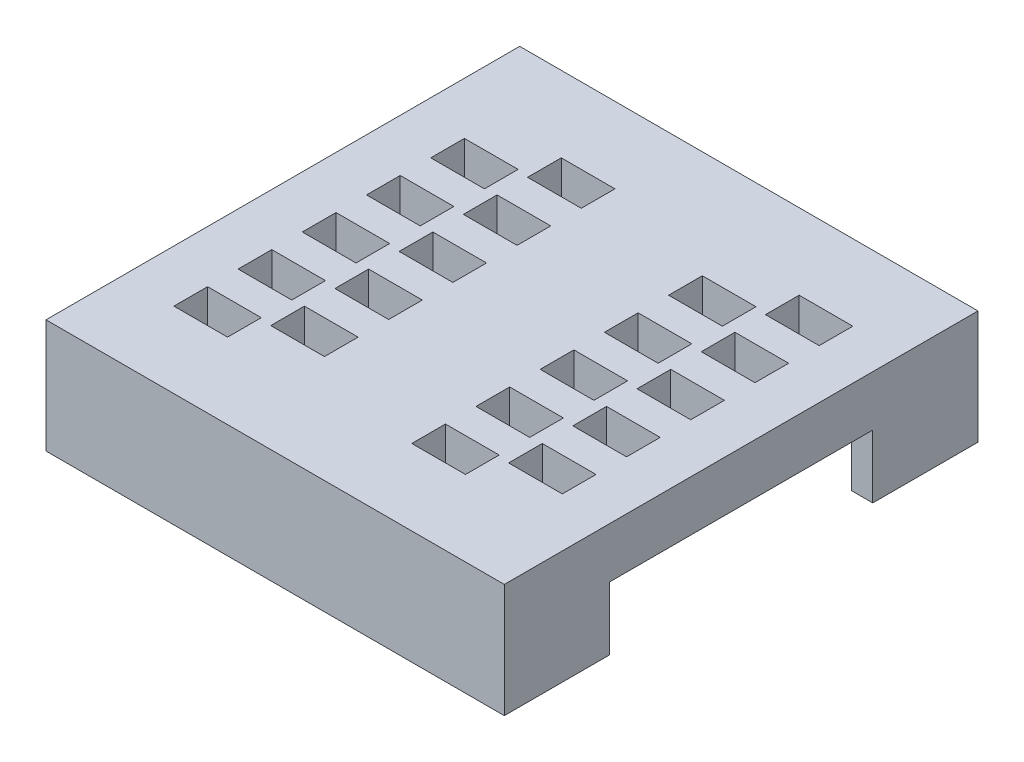
from build123d import *

# Parameters (mm, degrees)
SKETCH_1_W          = 43.5396
SKETCH_1_H          = 45
SKETCH_1_W_2        = 5.1
SKETCH_1_H_2        = 3.2
EXTRUDE_1_DEPTH     = 3.2
SKETCH_2_W          = 43.5396
SKETCH_2_H          = 45
SKETCH_2_R          = 0.5
SKETCH_2_W_2        = 5.6
SKETCH_2_H_2        = 5.6
EXTRUDE_3_DEPTH     = 0.6
SKETCH_3_R          = 5
SKETCH_3_R_2        = 0.5
EXTRUDE_4_DEPTH     = 1
SKETCH_4_W          = 43.5396
SKETCH_4_H          = 45
SKETCH_4_W_2        = 39.5396
SKETCH_4_H_2        = 41
EXTRUDE_6_DEPTH     = 7
SKETCH_6_W          = 2
SKETCH_6_H          = 25
CUT_EXTRUDE_2_DEPTH = 6
SKETCH_8_W          = 0.666666666
SKETCH_8_H          = 0.76923077
SKETCH_8_W_2        = 2.923076924
CUT_EXTRUDE_4_DEPTH = 0.2


with BuildPart() as part:
    # Эскиз1 → Бобышка-Вытянуть1 (new body)
    with BuildSketch(Plane(origin=(0, 0, 0), x_dir=(1, 0, 0), z_dir=(0, 1, 0))):
        with Locations((24.572876455, 25.0812132)):
            Rectangle(SKETCH_1_W, SKETCH_1_H)
        with Locations((16.503076455, 38.7809132)):
            Rectangle(SKETCH_1_W_2, SKETCH_1_H_2, mode=Mode.SUBTRACT)
        with Locations((39.103076455, 38.7809132)):
            Rectangle(SKETCH_1_W_2, SKETCH_1_H_2, mode=Mode.SUBTRACT)
        with Locations((10.303076455, 35.7809132)):
            Rectangle(SKETCH_1_W_2, SKETCH_1_H_2, mode=Mode.SUBTRACT)
        with Locations((32.903076455, 35.7809132)):
            Rectangle(SKETCH_1_W_2, SKETCH_1_H_2, mode=Mode.SUBTRACT)
        with Locations((16.503076455, 32.6809132)):
            Rectangle(SKETCH_1_W_2, SKETCH_1_H_2, mode=Mode.SUBTRACT)
        with Locations((39.103076455, 32.6809132)):
            Rectangle(SKETCH_1_W_2, SKETCH_1_H_2, mode=Mode.SUBTRACT)
        with Locations((10.303076455, 29.6809132)):
            Rectangle(SKETCH_1_W_2, SKETCH_1_H_2, mode=Mode.SUBTRACT)
        with Locations((32.903076455, 29.6809132)):
            Rectangle(SKETCH_1_W_2, SKETCH_1_H_2, mode=Mode.SUBTRACT)
        with Locations((39.103076455, 26.5809132)):
            Rectangle(SKETCH_1_W_2, SKETCH_1_H_2, mode=Mode.SUBTRACT)
        with Locations((16.503076455, 26.5809132)):
            Rectangle(SKETCH_1_W_2, SKETCH_1_H_2, mode=Mode.SUBTRACT)
        with Locations((10.303076455, 23.5809132)):
            Rectangle(SKETCH_1_W_2, SKETCH_1_H_2, mode=Mode.SUBTRACT)
        with Locations((32.903076455, 23.5809132)):
            Rectangle(SKETCH_1_W_2, SKETCH_1_H_2, mode=Mode.SUBTRACT)
        with Locations((39.103076455, 20.4809132)):
            Rectangle(SKETCH_1_W_2, SKETCH_1_H_2, mode=Mode.SUBTRACT)
        with Locations((16.503076455, 20.4809132)):
            Rectangle(SKETCH_1_W_2, SKETCH_1_H_2, mode=Mode.SUBTRACT)
        with Locations((32.903076455, 17.4809132)):
            Rectangle(SKETCH_1_W_2, SKETCH_1_H_2, mode=Mode.SUBTRACT)
        with Locations((10.303076455, 17.4809132)):
            Rectangle(SKETCH_1_W_2, SKETCH_1_H_2, mode=Mode.SUBTRACT)
        with Locations((16.503076455, 14.3809132)):
            Rectangle(SKETCH_1_W_2, SKETCH_1_H_2, mode=Mode.SUBTRACT)
        with Locations((10.303076455, 11.3809132)):
            Rectangle(SKETCH_1_W_2, SKETCH_1_H_2, mode=Mode.SUBTRACT)
        with Locations((32.903076455, 11.3809132)):
            Rectangle(SKETCH_1_W_2, SKETCH_1_H_2, mode=Mode.SUBTRACT)
        with Locations((39.103076455, 14.3809132)):
            Rectangle(SKETCH_1_W_2, SKETCH_1_H_2, mode=Mode.SUBTRACT)
    extrude(amount=EXTRUDE_1_DEPTH)

    # Эскиз2 → Бобышка-Вытянуть3 (add)
    with BuildSketch(Plane(origin=(0, 0, 0), x_dir=(1, 0, 0), z_dir=(0, 1, 0))):
        with Locations((24.572876455, 25.0812132)):
            Rectangle(SKETCH_2_W, SKETCH_2_H)
        with Locations((7.803076455, 42.5812132)):
            Circle(SKETCH_2_R, mode=Mode.SUBTRACT)
        with Locations((41.342676455, 42.5812132)):
            Circle(SKETCH_2_R, mode=Mode.SUBTRACT)
        with Locations((41.342676455, 7.5812132)):
            Circle(SKETCH_2_R, mode=Mode.SUBTRACT)
        with Locations((7.803076455, 7.5812132)):
            Circle(SKETCH_2_R, mode=Mode.SUBTRACT)
        with Locations((16.503076455, 38.7812132)):
            Rectangle(SKETCH_2_W_2, SKETCH_2_H_2, mode=Mode.SUBTRACT)
        with Locations((16.503076455, 32.624117539)):
            Rectangle(SKETCH_2_W_2, SKETCH_2_H_2, mode=Mode.SUBTRACT)
        with Locations((16.503076455, 26.5812132)):
            Rectangle(SKETCH_2_W_2, SKETCH_2_H_2, mode=Mode.SUBTRACT)
        with Locations((16.503076455, 20.4812132)):
            Rectangle(SKETCH_2_W_2, SKETCH_2_H_2, mode=Mode.SUBTRACT)
        with Locations((16.503076455, 14.3812132)):
            Rectangle(SKETCH_2_W_2, SKETCH_2_H_2, mode=Mode.SUBTRACT)
        with Locations((32.903076455, 11.3812132)):
            Rectangle(SKETCH_2_W_2, SKETCH_2_H_2, mode=Mode.SUBTRACT)
        with Locations((32.903076455, 17.4812132)):
            Rectangle(SKETCH_2_W_2, SKETCH_2_H_2, mode=Mode.SUBTRACT)
        with Locations((32.903076455, 23.5812132)):
            Rectangle(SKETCH_2_W_2, SKETCH_2_H_2, mode=Mode.SUBTRACT)
        with Locations((32.903076455, 29.6812132)):
            Rectangle(SKETCH_2_W_2, SKETCH_2_H_2, mode=Mode.SUBTRACT)
        with Locations((32.903076455, 35.7812132)):
            Rectangle(SKETCH_2_W_2, SKETCH_2_H_2, mode=Mode.SUBTRACT)
    extrude(amount=-EXTRUDE_3_DEPTH)

    # Эскиз3 → Бобышка-Вытянуть4 (add)
    with BuildSketch(Plane.XZ.offset(0.6)):
        with Locations((7.803076455, -7.5812132)):
            Circle(SKETCH_3_R)
        with Locations((7.803076455, -7.5812132)):
            Circle(SKETCH_3_R_2, mode=Mode.SUBTRACT)
        with Locations((41.342676455, -7.5812132)):
            Circle(SKETCH_3_R)
        with Locations((41.342676455, -7.5812132)):
            Circle(SKETCH_3_R_2, mode=Mode.SUBTRACT)
        with Locations((41.342676455, -42.5812132)):
            Circle(SKETCH_3_R)
        with Locations((41.342676455, -42.5812132)):
            Circle(SKETCH_3_R_2, mode=Mode.SUBTRACT)
        with Locations((7.803076455, -42.5812132)):
            Circle(SKETCH_3_R)
        with Locations((7.803076455, -42.5812132)):
            Circle(SKETCH_3_R_2, mode=Mode.SUBTRACT)
    extrude(amount=EXTRUDE_4_DEPTH)

    # Эскиз4 → Бобышка-Вытянуть6 (add)
    with BuildSketch(Plane.XZ.offset(0.6)):
        with Locations((24.572876455, -25.0812132)):
            Rectangle(SKETCH_4_W, SKETCH_4_H)
        with Locations((24.572876455, -25.0812132)):
            Rectangle(SKETCH_4_W_2, SKETCH_4_H_2, mode=Mode.SUBTRACT)
    extrude(amount=EXTRUDE_6_DEPTH)

    # Эскиз6 → Вырез-Вытянуть2 (cut)
    with BuildSketch(Plane.XZ.offset(7.6)):
        with Locations((3.803076455, -25.0812132)):
            Rectangle(SKETCH_6_W, SKETCH_6_H)
        with Locations((45.342676455, -25.0812132)):
            Rectangle(SKETCH_6_W, SKETCH_6_H)
    extrude(amount=-CUT_EXTRUDE_2_DEPTH, mode=Mode.SUBTRACT)

    # Эскиз8 → Вырез-Вытянуть4 (cut)
    with BuildSketch(Plane.XZ.offset(0.6)):
        with BuildLine():
            Line((22.803076455, -17.437559656), (22.803076455, -16.668328887))
            Line((22.803076455, -16.668328887), (23.225352096, -16.668328887))
            add(Edge.make_bspline(
                [(23.225352096, -16.668328887), (23.186037635, -16.640249012), (23.109623847, -16.585671397), (23.011636099, -16.48835605), (22.927633688, -16.386202085), (22.862878338, -16.275193724), (22.813636699, -16.161029567), (22.777804078, -16.045577461), (22.756203694, -15.92928801), (22.753260637, -15.851375651), (22.751794404, -15.812559656)],
                knots=[0, 0, 0, 0, 0.000144713, 0.000281272, 0.000412919, 0.000540446, 0.000665336, 0.000785221, 0.000902471, 0.001018881, 0.001018881, 0.001018881, 0.001018881], degree=3))
            add(Edge.make_bspline(
                [(22.751794404, -15.812559656), (22.753114243, -15.774038075), (22.755732457, -15.697621352), (22.773947574, -15.585161556), (22.807014692, -15.477430914), (22.85086947, -15.373737911), (22.907960308, -15.274253997), (22.976625811, -15.17860401), (23.05995328, -15.088655398), (23.153417868, -15.002274282), (23.259379923, -14.924093411), (23.37497246, -14.854682088), (23.501155539, -14.79694285), (23.63698816, -14.749835125), (23.782848054, -14.713055223), (23.938492059, -14.686746063), (24.104065225, -14.671785841), (24.217576453, -14.669501341), (24.275832866, -14.668328887)],
                knots=[0, 0, 0, 0, 0.000115563, 0.000229246, 0.000340532, 0.0004529, 0.0005663, 0.000683947, 0.00080533, 0.000933505, 0.001065238, 0.001199633, 0.001337305, 0.001480736, 0.001630379, 0.001788061, 0.001953825, 0.002128595, 0.002128595, 0.002128595, 0.002128595], degree=3))
            add(Edge.make_bspline(
                [(24.275832866, -14.668328887), (24.335423994, -14.669494736), (24.451067804, -14.671757209), (24.619055365, -14.686636933), (24.775773468, -14.71298266), (24.921661804, -14.749718407), (25.056724482, -14.796820967), (25.18119295, -14.854368041), (25.293784325, -14.923692762), (25.395092545, -15.002456968), (25.484702263, -15.089011869), (25.563143362, -15.18145491), (25.62911697, -15.280028589), (25.684295407, -15.383588703), (25.726079133, -15.49353784), (25.755251544, -15.608650295), (25.774874351, -15.729091921), (25.776570005, -15.811411123), (25.77743543, -15.853425041)],
                knots=[0, 0, 0, 0, 0.000178774, 0.000346932, 0.000505404, 0.000655047, 0.000797722, 0.00093394, 0.001065594, 0.001193499, 0.001318169, 0.001438719, 0.001556505, 0.001673352, 0.00179002, 0.001908377, 0.002029182, 0.002155108, 0.002155108, 0.002155108, 0.002155108], degree=3))
            add(Edge.make_bspline(
                [(25.77743543, -15.853425041), (25.776187089, -15.892229818), (25.773727633, -15.96868221), (25.754633801, -16.081361273), (25.723678883, -16.189915818), (25.678609093, -16.294096292), (25.622490944, -16.39490195), (25.553028692, -16.491038977), (25.471436488, -16.583429712), (25.409423222, -16.639534039), (25.377595686, -16.668328887)],
                knots=[0, 0, 0, 0, 0.000116363, 0.000229255, 0.000341852, 0.00045422, 0.000569016, 0.000687313, 0.000809353, 0.00093803, 0.00093803, 0.00093803, 0.00093803], degree=3))
            Line((25.377595686, -16.668328887), (26.803076455, -16.668328887))
            Line((26.803076455, -16.668328887), (26.803076455, -17.437559656))
            Line((26.803076455, -17.437559656), (22.803076455, -17.437559656))
        make_face()
        with BuildLine():
            add(Edge.make_bspline(
                [(24.319903379, -15.437559656), (24.281162804, -15.437685924), (24.206560259, -15.437929077), (24.098868363, -15.444843294), (23.999698249, -15.454248702), (23.908575819, -15.466499541), (23.825855053, -15.484132497), (23.751499301, -15.505736617), (23.684791651, -15.529924985), (23.645027831, -15.550911141), (23.625993122, -15.560957092)],
                knots=[0, 0, 0, 0, 0.000116197, 0.00022376, 0.000323583, 0.000415031, 0.000499425, 0.000577021, 0.000647265, 0.000711767, 0.000711767, 0.000711767, 0.000711767], degree=3))
            add(Edge.make_bspline(
                [(23.625993122, -15.560957092), (23.601241414, -15.575810985), (23.553347257, -15.604553028), (23.490712713, -15.656993574), (23.435927957, -15.711861393), (23.392449426, -15.773148598), (23.357368509, -15.83803226), (23.333486064, -15.907924354), (23.318445586, -15.981785709), (23.316759591, -16.032569959), (23.315896968, -16.058553246)],
                knots=[0, 0, 0, 0, 8.6468e-05, 0.000167314, 0.000244379, 0.000318431, 0.000391914, 0.000464897, 0.000539226, 0.000617099, 0.000617099, 0.000617099, 0.000617099], degree=3))
            add(Edge.make_bspline(
                [(23.315896968, -16.058553246), (23.31679995, -16.079420138), (23.318582326, -16.120608821), (23.32872754, -16.181140578), (23.347788772, -16.238850121), (23.373600842, -16.294074936), (23.405739883, -16.347761222), (23.446346159, -16.398189247), (23.493948131, -16.446391964), (23.548401932, -16.492109916), (23.610156931, -16.533966216), (23.679615877, -16.569936591), (23.756351358, -16.60061754), (23.840308362, -16.62454231), (23.930812537, -16.645454185), (24.028773459, -16.657957695), (24.13381546, -16.667565084), (24.206362763, -16.668068983), (24.243781584, -16.668328887)],
                knots=[0, 0, 0, 0, 6.2628e-05, 0.000123621, 0.000183422, 0.000244367, 0.000306206, 0.000370653, 0.00043808, 0.000509178, 0.000583628, 0.000661402, 0.000743388, 0.000831112, 0.000923065, 0.001021766, 0.001127103, 0.001239308, 0.001239308, 0.001239308, 0.001239308], degree=3))
            add(Edge.make_bspline(
                [(24.243781584, -16.668328887), (24.285195326, -16.667963686), (24.365169211, -16.667258449), (24.480731637, -16.659173751), (24.587555422, -16.645902198), (24.685241451, -16.626720212), (24.77411897, -16.603012036), (24.853938703, -16.573475231), (24.924681948, -16.538404859), (24.98658965, -16.498018665), (25.039489143, -16.452434507), (25.086247892, -16.404887834), (25.125133783, -16.35349909), (25.157569191, -16.299707049), (25.182671758, -16.242328925), (25.199960004, -16.18165307), (25.211985308, -16.118321496), (25.212880249, -16.0749031), (25.213332866, -16.052944271)],
                knots=[0, 0, 0, 0, 0.000124222, 0.000239884, 0.000347322, 0.000446952, 0.000538312, 0.000622998, 0.000701834, 0.000774729, 0.000844085, 0.000910952, 0.000974416, 0.001036941, 0.001099019, 0.001161647, 0.001225934, 0.001291718, 0.001291718, 0.001291718, 0.001291718], degree=3))
            add(Edge.make_bspline(
                [(25.213332866, -16.052944271), (25.212789456, -16.031533809), (25.211716275, -15.989250217), (25.201022848, -15.927331701), (25.18331783, -15.86809629), (25.158033501, -15.81186672), (25.126925991, -15.757716532), (25.087768111, -15.706921324), (25.041764512, -15.658687262), (24.988985893, -15.613238678), (24.929599649, -15.571090677), (24.862679302, -15.53531432), (24.789180435, -15.504663897), (24.708636101, -15.480012835), (24.621245246, -15.46092972), (24.526940834, -15.44778428), (24.425862434, -15.438354789), (24.355984962, -15.437830418), (24.319903379, -15.437559656)],
                knots=[0, 0, 0, 0, 6.4183e-05, 0.000126755, 0.000187847, 0.000249191, 0.000311309, 0.000374773, 0.000441086, 0.000510963, 0.000583433, 0.000659086, 0.000738104, 0.000821995, 0.000911426, 0.001006161, 0.001107506, 0.001215706, 0.001215706, 0.001215706, 0.001215706], degree=3))
        make_face(mode=Mode.SUBTRACT)
        with Locations((26.469743122, -18.642687861)):
            Rectangle(SKETCH_8_W, SKETCH_8_H)
        with Locations((24.264614917, -18.642687861)):
            Rectangle(SKETCH_8_W_2, SKETCH_8_H)
        with BuildLine():
            Line((25.726153379, -19.796534015), (25.726153379, -20.565764784))
            Line((25.726153379, -20.565764784), (25.30467902, -20.565764784))
            add(Edge.make_bspline(
                [(25.30467902, -20.565764784), (25.339518686, -20.588657143), (25.409008287, -20.634317194), (25.501569561, -20.718536511), (25.581986338, -20.815097089), (25.651726934, -20.921252245), (25.708086459, -21.036588407), (25.748065445, -21.159282011), (25.773071082, -21.288042482), (25.775964547, -21.376013155), (25.77743543, -21.420732733)],
                knots=[0, 0, 0, 0, 0.00012492, 0.00024916, 0.00037371, 0.000501056, 0.000629351, 0.000757566, 0.000887218, 0.001021272, 0.001021272, 0.001021272, 0.001021272], degree=3))
            add(Edge.make_bspline(
                [(25.77743543, -21.420732733), (25.77617725, -21.459802629), (25.773689763, -21.537045844), (25.754695085, -21.650471339), (25.724278581, -21.759739802), (25.680773848, -21.864463906), (25.624102022, -21.964212204), (25.555527488, -22.059261419), (25.474479955, -22.149505402), (25.382244354, -22.234688888), (25.278623047, -22.31267788), (25.16483239, -22.380828245), (25.040758179, -22.437767376), (24.907648015, -22.485359694), (24.764137136, -22.520655995), (24.611615067, -22.547459937), (24.449201649, -22.562283578), (24.337826731, -22.564583747), (24.280640558, -22.565764784)],
                knots=[0, 0, 0, 0, 0.000117163, 0.000231637, 0.000344013, 0.000456809, 0.000570907, 0.000687435, 0.000807745, 0.000934198, 0.001063525, 0.001196134, 0.001331287, 0.001472452, 0.001619567, 0.00177409, 0.001936663, 0.002108229, 0.002108229, 0.002108229, 0.002108229], degree=3))
            add(Edge.make_bspline(
                [(24.280640558, -22.565764784), (24.221837754, -22.56470628), (24.107477326, -22.562647689), (23.941242923, -22.54620756), (23.78473337, -22.520710041), (23.638741952, -22.481487307), (23.501686183, -22.434236249), (23.375389667, -22.374506491), (23.258781046, -22.304611642), (23.153728516, -22.22357911), (23.059282379, -22.135845135), (22.976886758, -22.042587653), (22.907610158, -21.944484152), (22.850910693, -21.84181281), (22.806642668, -21.734548424), (22.774210232, -21.62289645), (22.755597619, -21.50629307), (22.753074608, -21.427207688), (22.751794404, -21.387078887)],
                knots=[0, 0, 0, 0, 0.000176371, 0.000343009, 0.000500691, 0.000651511, 0.000795964, 0.000935039, 0.001069847, 0.001203026, 0.001332289, 0.00145606, 0.001575664, 0.001691861, 0.001807184, 0.001923082, 0.002039929, 0.002160292, 0.002160292, 0.002160292, 0.002160292], degree=3))
            add(Edge.make_bspline(
                [(22.751794404, -21.387078887), (22.752639788, -21.349055324), (22.754299474, -21.274406193), (22.774281949, -21.165584448), (22.801927333, -21.061463463), (22.84527722, -20.962050754), (22.902769091, -20.864547088), (22.9756812, -20.76544306), (23.065970637, -20.664492402), (23.134817053, -20.599693419), (23.170864917, -20.565764784)],
                knots=[0, 0, 0, 0, 0.00011392, 0.000223652, 0.000330967, 0.000436496, 0.000547814, 0.000669938, 0.00080502, 0.000953484, 0.000953484, 0.000953484, 0.000953484], degree=3))
            Line((23.170864917, -20.565764784), (21.726153379, -20.565764784))
            Line((21.726153379, -20.565764784), (21.726153379, -19.796534015))
            Line((21.726153379, -19.796534015), (25.726153379, -19.796534015))
        make_face()
        with BuildLine():
            add(Edge.make_bspline(
                [(24.314294404, -20.565764784), (24.273150717, -20.566492315), (24.193455359, -20.567901542), (24.078097864, -20.575506711), (23.970927221, -20.589628524), (23.872339445, -20.610873078), (23.78131112, -20.635615372), (23.699120744, -20.66809285), (23.62492036, -20.7053274), (23.559779712, -20.749023399), (23.502555691, -20.796540734), (23.45297847, -20.846826008), (23.410499147, -20.899514321), (23.375791074, -20.954817827), (23.349288692, -21.013138818), (23.329585173, -21.073786593), (23.318421242, -21.137203116), (23.316741596, -21.18030733), (23.315896968, -21.201982733)],
                knots=[0, 0, 0, 0, 0.000123439, 0.000239102, 0.000346644, 0.000447379, 0.000541485, 0.000629275, 0.000712056, 0.000790061, 0.000864031, 0.000934857, 0.001001556, 0.001066702, 0.001130165, 0.001193263, 0.001257551, 0.001322578, 0.001322578, 0.001322578, 0.001322578], degree=3))
            add(Edge.make_bspline(
                [(23.315896968, -21.201982733), (23.316440152, -21.222860081), (23.317512721, -21.264084394), (23.328206318, -21.324414752), (23.345927134, -21.382055666), (23.371215775, -21.436687129), (23.402355098, -21.489226511), (23.441474973, -21.538473363), (23.487559638, -21.584666992), (23.539516362, -21.629728574), (23.601093356, -21.668580849), (23.670808611, -21.703349238), (23.749366097, -21.733006687), (23.837374635, -21.755576819), (23.933990615, -21.774001252), (24.039411142, -21.787379747), (24.1539098, -21.795479963), (24.233083639, -21.796173555), (24.274230302, -21.796534015)],
                knots=[0, 0, 0, 0, 6.2582e-05, 0.000123574, 0.000183134, 0.000243016, 0.000303755, 0.000365951, 0.000431112, 0.000499339, 0.000571796, 0.00064884, 0.000732776, 0.000823154, 0.000921058, 0.001027701, 0.001141765, 0.001265186, 0.001265186, 0.001265186, 0.001265186], degree=3))
            add(Edge.make_bspline(
                [(24.274230302, -21.796534015), (24.31271582, -21.79627309), (24.387126919, -21.795768595), (24.494855048, -21.78623022), (24.595087898, -21.773401649), (24.68758071, -21.753743542), (24.773002634, -21.730589863), (24.849994374, -21.699733593), (24.919872781, -21.664646103), (24.981503443, -21.623431842), (25.036354612, -21.578912162), (25.082625269, -21.530169524), (25.123588714, -21.480476705), (25.156678894, -21.427496028), (25.181560744, -21.371210329), (25.200298661, -21.313029061), (25.210727059, -21.251762007), (25.212453001, -21.210299378), (25.213332866, -21.18916222)],
                knots=[0, 0, 0, 0, 0.00011541, 0.000223143, 0.000324225, 0.000418358, 0.00050663, 0.00058936, 0.000666766, 0.00074077, 0.000811356, 0.000878223, 0.000942045, 0.001004303, 0.001064915, 0.001126243, 0.001187236, 0.001250664, 0.001250664, 0.001250664, 0.001250664], degree=3))
            add(Edge.make_bspline(
                [(25.213332866, -21.18916222), (25.212897689, -21.167201335), (25.212042449, -21.124042216), (25.199881909, -21.060993269), (25.182490202, -21.000396692), (25.157820573, -20.942547735), (25.124886587, -20.888513018), (25.086305749, -20.836425086), (25.039548422, -20.788027551), (24.98651491, -20.741976971), (24.926327251, -20.700151254), (24.858689056, -20.664231379), (24.784418376, -20.63405428), (24.704006324, -20.607931598), (24.616154009, -20.589137319), (24.521596885, -20.576036196), (24.42025302, -20.566553778), (24.350375837, -20.566033455), (24.314294404, -20.565764784)],
                knots=[0, 0, 0, 0, 6.5783e-05, 0.000129282, 0.00019191, 0.000254723, 0.000317249, 0.000381351, 0.000448797, 0.000518674, 0.000591802, 0.000668159, 0.000747918, 0.000832049, 0.000921481, 0.001017008, 0.001118354, 0.001226554, 0.001226554, 0.001226554, 0.001226554], degree=3))
        make_face(mode=Mode.SUBTRACT)
        with BuildLine():
            Line((23.947307225, -22.976021194), (24.033845686, -23.642687861))
            add(Edge.make_bspline(
                [(24.033845686, -23.642687861), (23.988647068, -23.650084149), (23.901609681, -23.664326919), (23.779768738, -23.708176139), (23.673192798, -23.770687781), (23.582723505, -23.849384413), (23.509736579, -23.939156067), (23.45698064, -24.037831604), (23.42430572, -24.143311055), (23.420418254, -24.216444854), (23.418461071, -24.253264784)],
                knots=[0, 0, 0, 0, 0.000137188, 0.000264178, 0.000385936, 0.000505788, 0.000622043, 0.000731018, 0.000839771, 0.00095004, 0.00095004, 0.00095004, 0.00095004], degree=3))
            add(Edge.make_bspline(
                [(23.418461071, -24.253264784), (23.418836881, -24.274659003), (23.419572536, -24.316538515), (23.427925417, -24.378253311), (23.441491252, -24.437210609), (23.459918768, -24.493955543), (23.484095871, -24.547943525), (23.514008864, -24.59923729), (23.54864059, -24.648468452), (23.588285748, -24.695010356), (23.634442295, -24.73678113), (23.685496217, -24.773879359), (23.742672226, -24.804230098), (23.804377266, -24.830395547), (23.872422945, -24.848906189), (23.945148578, -24.863752685), (24.023541521, -24.871295181), (24.077369576, -24.872720982), (24.105159789, -24.873457092)],
                knots=[0, 0, 0, 0, 6.4148e-05, 0.00012557, 0.000186409, 0.000245449, 0.000304271, 0.000363506, 0.000423308, 0.000484668, 0.000546491, 0.000609645, 0.000673467, 0.000740281, 0.000810282, 0.000884612, 0.000962748, 0.001046143, 0.001046143, 0.001046143, 0.001046143], degree=3))
            add(Edge.make_bspline(
                [(24.105159789, -24.873457092), (24.131355716, -24.873041253), (24.181983663, -24.872237576), (24.255335009, -24.864781332), (24.323882528, -24.853336042), (24.387125001, -24.835128379), (24.446238235, -24.814333838), (24.499126639, -24.786297398), (24.548089279, -24.755534799), (24.590479141, -24.718037929), (24.627947977, -24.677188521), (24.661278539, -24.633659192), (24.689409867, -24.586869075), (24.712673071, -24.53726093), (24.730654653, -24.484620216), (24.742014114, -24.428832128), (24.750756752, -24.370523195), (24.751444878, -24.33049014), (24.751794404, -24.31015581)],
                knots=[0, 0, 0, 0, 7.8562e-05, 0.000151835, 0.000220996, 0.000286706, 0.000349073, 0.000408562, 0.000465903, 0.000522135, 0.000577708, 0.000632035, 0.000686316, 0.000741161, 0.000796147, 0.000852727, 0.000911767, 0.000972712, 0.000972712, 0.000972712, 0.000972712], degree=3))
            add(Edge.make_bspline(
                [(24.751794404, -24.31015581), (24.750872759, -24.284448486), (24.749034062, -24.233161971), (24.73408725, -24.157453858), (24.709753735, -24.083764051), (24.67587979, -24.012169142), (24.632194728, -23.942858547), (24.578553678, -23.876132347), (24.515879531, -23.810845151), (24.468524423, -23.770741967), (24.444102096, -23.750059656)],
                knots=[0, 0, 0, 0, 7.7073e-05, 0.000153762, 0.000230539, 0.000309395, 0.000390764, 0.000475734, 0.000565838, 0.000661794, 0.000661794, 0.000661794, 0.000661794], degree=3))
            Line((24.444102096, -23.750059656), (24.538653379, -23.078585297))
            Line((24.538653379, -23.078585297), (26.751794404, -23.540123758))
            Line((26.751794404, -23.540123758), (26.751794404, -25.488841707))
            Line((26.751794404, -25.488841707), (25.982563635, -25.488841707))
            Line((25.982563635, -25.488841707), (25.982563635, -24.157110938))
            Line((25.982563635, -24.157110938), (25.268621327, -24.000059656))
            add(Edge.make_bspline(
                [(25.268621327, -24.000059656), (25.291712285, -24.040080826), (25.336679772, -24.118018322), (25.382969675, -24.242446053), (25.41267928, -24.367512969), (25.41654378, -24.451821502), (25.418461071, -24.493649399)],
                knots=[0, 0, 0, 0, 0.000138388, 0.000269497, 0.000396823, 0.000522192, 0.000522192, 0.000522192, 0.000522192], degree=3))
            add(Edge.make_bspline(
                [(25.418461071, -24.493649399), (25.417402907, -24.532971178), (25.415312624, -24.610646923), (25.398162513, -24.724564886), (25.369897371, -24.833833871), (25.330563467, -24.938822852), (25.279006982, -25.038780876), (25.216693126, -25.134569647), (25.142540583, -25.224806267), (25.058690208, -25.310460293), (24.965919854, -25.388570754), (24.864758483, -25.456025351), (24.757725658, -25.514286592), (24.643638802, -25.561718148), (24.522339195, -25.597435469), (24.394871326, -25.624184289), (24.260430285, -25.63916879), (24.168763331, -25.641498855), (24.121986712, -25.642687861)],
                knots=[0, 0, 0, 0, 0.000117922, 0.000232941, 0.000344691, 0.000456011, 0.000568537, 0.000681438, 0.000798197, 0.00091832, 0.001040612, 0.001161287, 0.001282471, 0.001405684, 0.001531168, 0.001661287, 0.001795965, 0.001936301, 0.001936301, 0.001936301, 0.001936301], degree=3))
            add(Edge.make_bspline(
                [(24.121986712, -25.642687861), (24.0826958, -25.641622691), (24.004711191, -25.639508542), (23.889352397, -25.626932803), (23.777154446, -25.604092426), (23.668433007, -25.572862717), (23.562349787, -25.533487533), (23.46003618, -25.484512282), (23.360623383, -25.426540573), (23.297931279, -25.38171151), (23.266217481, -25.359034015)],
                knots=[0, 0, 0, 0, 0.000117887, 0.000233981, 0.000347597, 0.000460963, 0.000573034, 0.000686649, 0.000800851, 0.000917764, 0.000917764, 0.000917764, 0.000917764], degree=3))
            add(Edge.make_bspline(
                [(23.266217481, -25.359034015), (23.225374015, -25.325987968), (23.144989322, -25.260949504), (23.039361396, -25.149580267), (22.95029191, -25.028387714), (22.878121828, -24.897493356), (22.820274797, -24.757984398), (22.780767512, -24.608401208), (22.756111318, -24.449866212), (22.753254336, -24.340965064), (22.751794404, -24.285316066)],
                knots=[0, 0, 0, 0, 0.000157486, 0.000309951, 0.000458998, 0.000607493, 0.000757335, 0.00091089, 0.001070563, 0.001237422, 0.001237422, 0.001237422, 0.001237422], degree=3))
            add(Edge.make_bspline(
                [(22.751794404, -24.285316066), (22.752608896, -24.240399776), (22.754199236, -24.152698269), (22.769821127, -24.024243598), (22.795485057, -23.902328071), (22.830268731, -23.786371643), (22.876730171, -23.677475432), (22.931848579, -23.574302581), (22.998006203, -23.477640227), (23.074351931, -23.388056953), (23.158750687, -23.305799795), (23.25109433, -23.232428707), (23.349843008, -23.16714801), (23.455993305, -23.111202657), (23.568801113, -23.063524019), (23.688844481, -23.025560274), (23.81532288, -22.994302843), (23.90282547, -22.98218253), (23.947307225, -22.976021194)],
                knots=[0, 0, 0, 0, 0.000134701, 0.000263011, 0.000387476, 0.000508127, 0.000625547, 0.000742064, 0.000858523, 0.000976202, 0.001094632, 0.001211512, 0.001329521, 0.001449243, 0.001570977, 0.00169641, 0.001826623, 0.001961257, 0.001961257, 0.001961257, 0.001961257], degree=3))
        make_face()
        with BuildLine():
            Line((25.759005943, -28.565764784), (25.674871327, -27.796534015))
            add(Edge.make_bspline(
                [(25.674871327, -27.796534015), (25.711965279, -27.791506823), (25.781847669, -27.782035947), (25.877467567, -27.75173346), (25.959017131, -27.713165548), (26.024545786, -27.661571522), (26.075212059, -27.600516489), (26.111175708, -27.530829935), (26.132533412, -27.452689958), (26.135084919, -27.397900246), (26.136409789, -27.369450682)],
                knots=[0, 0, 0, 0, 0.000112102, 0.000211193, 0.000299704, 0.000381298, 0.000459269, 0.000535963, 0.000614884, 0.000700125, 0.000700125, 0.000700125, 0.000700125], degree=3))
            add(Edge.make_bspline(
                [(26.136409789, -27.369450682), (26.135938054, -27.350158544), (26.134999326, -27.311768165), (26.123081213, -27.255847914), (26.105394654, -27.201934066), (26.080345374, -27.150466633), (26.048023921, -27.101188822), (26.008043965, -27.054849771), (25.962512942, -27.009319083), (25.907532097, -26.967276656), (25.842430918, -26.92694184), (25.762734797, -26.892211932), (25.668517774, -26.861257142), (25.559318402, -26.834753217), (25.435829805, -26.810701177), (25.29755209, -26.790985333), (25.144361019, -26.77520883), (25.03707651, -26.767640228), (24.980961071, -26.763681451)],
                knots=[0, 0, 0, 0, 5.7781e-05, 0.000114982, 0.000170727, 0.000227708, 0.000286158, 0.000346997, 0.000411025, 0.000478983, 0.000554154, 0.000640231, 0.000739052, 0.000851381, 0.000977098, 0.001116366, 0.001270248, 0.001439005, 0.001439005, 0.001439005, 0.001439005], degree=3))
            add(Edge.make_bspline(
                [(24.980961071, -26.763681451), (25.007684319, -26.787972916), (25.060216999, -26.835725187), (25.128533151, -26.915771735), (25.186438327, -27.000155941), (25.234361256, -27.088589632), (25.27032245, -27.181936469), (25.297295148, -27.279233734), (25.312322236, -27.381539592), (25.314693948, -27.451135977), (25.315896968, -27.486437861)],
                knots=[0, 0, 0, 0, 0.000108256, 0.00021281, 0.000314825, 0.000414844, 0.000513795, 0.000614292, 0.000717187, 0.000823105, 0.000823105, 0.000823105, 0.000823105], degree=3))
            add(Edge.make_bspline(
                [(25.315896968, -27.486437861), (25.314758939, -27.526283403), (25.312511734, -27.604964196), (25.296447748, -27.721090372), (25.268330554, -27.832451953), (25.229136942, -27.939306954), (25.180740495, -28.042540002), (25.118801281, -28.140332915), (25.047462362, -28.234624972), (24.965342992, -28.322962056), (24.874526645, -28.403307923), (24.776920293, -28.474700983), (24.672453141, -28.534943231), (24.561447044, -28.583903482), (24.444051097, -28.621733731), (24.320656872, -28.648833084), (24.190529071, -28.665102933), (24.101734815, -28.66723665), (24.056281584, -28.668328887)],
                knots=[0, 0, 0, 0, 0.000119523, 0.000236015, 0.00035087, 0.000463415, 0.00057703, 0.000692203, 0.000809994, 0.00093133, 0.00105337, 0.001173254, 0.001293513, 0.001414411, 0.001536549, 0.001662918, 0.001792916, 0.001929249, 0.001929249, 0.001929249, 0.001929249], degree=3))
            add(Edge.make_bspline(
                [(24.056281584, -28.668328887), (24.008146582, -28.667341862), (23.914239802, -28.665416273), (23.777076618, -28.647758781), (23.64704048, -28.621302566), (23.524184642, -28.582331162), (23.408431483, -28.53298635), (23.300518176, -28.47139837), (23.199560291, -28.399795926), (23.106955461, -28.317480325), (23.023937522, -28.226065979), (22.950546147, -28.128502425), (22.889206168, -28.023749578), (22.838443273, -27.91331939), (22.800162761, -27.795931876), (22.772103126, -27.673144813), (22.754807142, -27.543819364), (22.752814272, -27.455509418), (22.751794404, -27.410316066)],
                knots=[0, 0, 0, 0, 0.00014434, 0.000281593, 0.000414229, 0.000541952, 0.000667577, 0.000791016, 0.000913971, 0.001038273, 0.00116192, 0.001283875, 0.001403846, 0.001525401, 0.001647787, 0.00177355, 0.001902855, 0.002038388, 0.002038388, 0.002038388, 0.002038388], degree=3))
            add(Edge.make_bspline(
                [(22.751794404, -27.410316066), (22.753149132, -27.361893531), (22.755812769, -27.26668621), (22.777733149, -27.12731327), (22.814818965, -26.994809345), (22.866610888, -26.869190898), (22.931757109, -26.749413828), (23.012680592, -26.636590351), (23.108609633, -26.531019447), (23.218245133, -26.431304772), (23.344882797, -26.340567089), (23.491249303, -26.263294105), (23.655741649, -26.197758872), (23.838781693, -26.14440359), (24.040354916, -26.103217165), (24.260478221, -26.074478211), (24.498787578, -26.055389541), (24.663880412, -26.05377864), (24.749390558, -26.052944271)],
                knots=[0, 0, 0, 0, 0.000145211, 0.000285511, 0.000421993, 0.000557103, 0.000692292, 0.00083015, 0.000972555, 0.001119487, 0.001274018, 0.001438564, 0.001614737, 0.001804385, 0.002009778, 0.002231322, 0.002470015, 0.002726487, 0.002726487, 0.002726487, 0.002726487], degree=3))
            add(Edge.make_bspline(
                [(24.749390558, -26.052944271), (24.837033067, -26.054140222), (25.006379517, -26.056451086), (25.250892602, -26.075046391), (25.476690044, -26.104583395), (25.683262656, -26.147611441), (25.871039061, -26.202647636), (26.040396619, -26.269370132), (26.190722212, -26.349455206), (26.321526962, -26.442566637), (26.43523072, -26.545016044), (26.533376367, -26.655098381), (26.61691294, -26.772393394), (26.685629495, -26.896898266), (26.737723129, -27.029635081), (26.775341248, -27.16934479), (26.799517816, -27.316262055), (26.801877855, -27.416898057), (26.803076455, -27.468008374)],
                knots=[0, 0, 0, 0, 0.000262899, 0.000507984, 0.000735193, 0.00094562, 0.001140333, 0.001321564, 0.001490777, 0.001649966, 0.00180202, 0.001949013, 0.002091529, 0.002233177, 0.002374532, 0.002518179, 0.002666643, 0.002819858, 0.002819858, 0.002819858, 0.002819858], degree=3))
            add(Edge.make_bspline(
                [(26.803076455, -27.468008374), (26.802427781, -27.50410978), (26.801159705, -27.574683412), (26.787665861, -27.678113498), (26.767089831, -27.776806698), (26.738331802, -27.871155449), (26.700516975, -27.960607819), (26.653714916, -28.044974195), (26.598971238, -28.124658955), (26.536337873, -28.199406742), (26.465609283, -28.268531344), (26.386992236, -28.33117673), (26.300322566, -28.386298731), (26.207280684, -28.436624126), (26.105804214, -28.478591854), (25.997107412, -28.514757359), (25.880874923, -28.54447697), (25.800248334, -28.558560651), (25.759005943, -28.565764784)],
                knots=[0, 0, 0, 0, 0.000108247, 0.00021161, 0.000312345, 0.000410433, 0.000507019, 0.000603137, 0.000699374, 0.000796633, 0.000895227, 0.000995589, 0.001097607, 0.001202999, 0.001312529, 0.001426553, 0.001546462, 0.001672028, 0.001672028, 0.001672028, 0.001672028], degree=3))
        make_face()
        with BuildLine():
            add(Edge.make_bspline(
                [(24.073909789, -26.822175041), (24.048504752, -26.822466619), (23.998864765, -26.823036347), (23.926838068, -26.83240102), (23.859297582, -26.845828808), (23.795944533, -26.864028724), (23.737348846, -26.888901401), (23.683439893, -26.919824721), (23.633176457, -26.954847436), (23.574815275, -27.008939172), (23.51272195, -27.082954436), (23.45817645, -27.181008573), (23.424030574, -27.286035242), (23.420329036, -27.358515067), (23.418461071, -27.395091707)],
                knots=[0, 0, 0, 0, 7.616e-05, 0.000148812, 0.000217484, 0.000282645, 0.000346194, 0.000407913, 0.000468832, 0.000529523, 0.000646173, 0.000756999, 0.000864454, 0.000973925, 0.000973925, 0.000973925, 0.000973925], degree=3))
            add(Edge.make_bspline(
                [(23.418461071, -27.395091707), (23.420019484, -27.429735925), (23.423052766, -27.497167135), (23.450666204, -27.593498751), (23.494560529, -27.681042451), (23.545394783, -27.745678361), (23.595127371, -27.790669258), (23.639313528, -27.819692224), (23.688835303, -27.844348378), (23.744048024, -27.864267006), (23.80430891, -27.880395675), (23.870309604, -27.891385342), (23.941843965, -27.897624592), (23.991365048, -27.898595271), (24.017018763, -27.899098117)],
                knots=[0, 0, 0, 0, 0.00010374, 0.00020192, 0.000297957, 0.000396067, 0.000446573, 0.000498576, 0.00055412, 0.000612173, 0.000674369, 0.000741025, 0.000812626, 0.000889587, 0.000889587, 0.000889587, 0.000889587], degree=3))
            add(Edge.make_bspline(
                [(24.017018763, -27.899098117), (24.043479374, -27.898671989), (24.094635689, -27.897848154), (24.168553418, -27.890550239), (24.236960137, -27.87881033), (24.29992013, -27.861773733), (24.357922665, -27.840886889), (24.409454141, -27.8127724), (24.456542838, -27.78189912), (24.510597073, -27.73374291), (24.565854918, -27.664260212), (24.615323613, -27.570745831), (24.643898509, -27.466445733), (24.647419365, -27.393928881), (24.649230302, -27.356630169)],
                knots=[0, 0, 0, 0, 7.9363e-05, 0.000153433, 0.000222595, 0.00028732, 0.000348935, 0.000407005, 0.000463009, 0.000517508, 0.000623501, 0.000727437, 0.000832993, 0.000944786, 0.000944786, 0.000944786, 0.000944786], degree=3))
            add(Edge.make_bspline(
                [(24.649230302, -27.356630169), (24.647740696, -27.320380927), (24.644847647, -27.249979215), (24.616286791, -27.148916569), (24.569958442, -27.05688259), (24.516521702, -26.988613541), (24.465363443, -26.940848996), (24.422992117, -26.908101677), (24.374930119, -26.882223899), (24.323583135, -26.859058844), (24.267113799, -26.842775988), (24.206551331, -26.830683703), (24.141657533, -26.823477376), (24.096897876, -26.822616947), (24.073909789, -26.822175041)],
                knots=[0, 0, 0, 0, 0.000108532, 0.000210785, 0.000312197, 0.000416068, 0.000468788, 0.000521994, 0.000576162, 0.000632137, 0.000690696, 0.000751983, 0.000817286, 0.000886238, 0.000886238, 0.000886238, 0.000886238], degree=3))
        make_face(mode=Mode.SUBTRACT)
        with BuildLine():
            Line((23.572307225, -31.745251964), (22.803076455, -31.745251964))
            Line((22.803076455, -31.745251964), (22.803076455, -29.129867348))
            add(Edge.make_bspline(
                [(22.803076455, -29.129867348), (22.868812521, -29.138739606), (23.000247793, -29.156479146), (23.192441398, -29.210986318), (23.379558702, -29.285085227), (23.531682703, -29.364707315), (23.655383609, -29.442131085), (23.754845625, -29.514977962), (23.862778887, -29.599096782), (23.976660553, -29.697299309), (24.098702046, -29.80713552), (24.227827453, -29.929971513), (24.363569413, -30.066194693), (24.455738325, -30.162039002), (24.503396968, -30.211598117)],
                knots=[0, 0, 0, 0, 0.000198786, 0.00039746, 0.000597441, 0.000801728, 0.000911551, 0.001034972, 0.00117138, 0.001321998, 0.001485963, 0.001663931, 0.001856572, 0.00206284, 0.00206284, 0.00206284, 0.00206284], degree=3))
            add(Edge.make_bspline(
                [(24.503396968, -30.211598117), (24.541564567, -30.251153714), (24.614224433, -30.32645592), (24.71838167, -30.433570379), (24.813618005, -30.527999093), (24.899327995, -30.610288167), (24.974545845, -30.681532898), (25.041013103, -30.739818027), (25.097484847, -30.786961181), (25.133336772, -30.812469502), (25.149230302, -30.823777605)],
                knots=[0, 0, 0, 0, 0.000164903, 0.000313926, 0.000448209, 0.000567215, 0.000670391, 0.000758961, 0.000832421, 0.000890921, 0.000890921, 0.000890921, 0.000890921], degree=3))
            add(Edge.make_bspline(
                [(25.149230302, -30.823777605), (25.187657826, -30.847053173), (25.26169269, -30.891896122), (25.378920345, -30.939332407), (25.495117526, -30.970292677), (25.573191957, -30.974133304), (25.611570045, -30.976021194)],
                knots=[0, 0, 0, 0, 0.00013457, 0.000259264, 0.0003782, 0.000493186, 0.000493186, 0.000493186, 0.000493186], degree=3))
            add(Edge.make_bspline(
                [(25.611570045, -30.976021194), (25.651491631, -30.974607351), (25.727020157, -30.971932468), (25.833313004, -30.948760454), (25.925335581, -30.909448201), (26.002001678, -30.853395357), (26.062592107, -30.782799369), (26.106653645, -30.699771245), (26.131519861, -30.604019938), (26.134731337, -30.536796166), (26.136409789, -30.50166222)],
                knots=[0, 0, 0, 0, 0.00011966, 0.000226387, 0.000324343, 0.000417778, 0.000508687, 0.000601165, 0.000697375, 0.000802713, 0.000802713, 0.000802713, 0.000802713], degree=3))
            add(Edge.make_bspline(
                [(26.136409789, -30.50166222), (26.134829103, -30.466773271), (26.131775558, -30.399375355), (26.105100213, -30.303588293), (26.058922385, -30.219792292), (26.006298295, -30.160074805), (25.955125189, -30.11973281), (25.910531199, -30.092245182), (25.859858751, -30.068552993), (25.803678331, -30.047559736), (25.741346335, -30.030977437), (25.673337483, -30.017623083), (25.59928579, -30.006861406), (25.547770147, -30.003439002), (25.521025173, -30.00166222)],
                knots=[0, 0, 0, 0, 0.000104539, 0.000201947, 0.000295185, 0.00038941, 0.000438465, 0.000490276, 0.000546188, 0.000606022, 0.000669974, 0.000739432, 0.000813882, 0.000894267, 0.000894267, 0.000894267, 0.000894267], degree=3))
            Line((25.521025173, -30.00166222), (25.596345686, -29.232431451))
            add(Edge.make_bspline(
                [(25.596345686, -29.232431451), (25.648278459, -29.238615947), (25.748967807, -29.250606697), (25.893592428, -29.280529815), (26.02701517, -29.318426335), (26.148988423, -29.366102912), (26.26028782, -29.421589015), (26.359243242, -29.487714897), (26.446950838, -29.56217005), (26.523363925, -29.645018819), (26.588725596, -29.735734509), (26.647070917, -29.830924348), (26.694932627, -29.932448612), (26.734377868, -30.039189515), (26.765902188, -30.151098819), (26.786745642, -30.26869412), (26.801407007, -30.391249664), (26.802511586, -30.474906589), (26.803076455, -30.517687861)],
                knots=[0, 0, 0, 0, 0.000156839, 0.000304085, 0.000442547, 0.000572448, 0.000696438, 0.000814889, 0.00092857, 0.001040846, 0.001152072, 0.001263519, 0.001375343, 0.001488165, 0.001604616, 0.001723586, 0.001846141, 0.001974408, 0.001974408, 0.001974408, 0.001974408], degree=3))
            add(Edge.make_bspline(
                [(26.803076455, -30.517687861), (26.802182667, -30.564196691), (26.800441902, -30.654778477), (26.786064076, -30.787010794), (26.761000558, -30.911237316), (26.727779935, -31.028526863), (26.6835007, -31.137735911), (26.629611567, -31.239750403), (26.56525806, -31.333533735), (26.492228733, -31.419187016), (26.412751985, -31.496063966), (26.326636877, -31.5618811), (26.237257431, -31.619664303), (26.141604474, -31.665023999), (26.042077395, -31.701979944), (25.936920128, -31.725758806), (25.82769028, -31.743147048), (25.752936052, -31.744542565), (25.71493543, -31.745251964)],
                knots=[0, 0, 0, 0, 0.000139506, 0.000271705, 0.000398364, 0.000519325, 0.000636874, 0.000751222, 0.000864792, 0.000977343, 0.001088418, 0.001195802, 0.001302058, 0.001407063, 0.001512762, 0.00161985, 0.001729996, 0.00184388, 0.00184388, 0.00184388, 0.00184388], degree=3))
            add(Edge.make_bspline(
                [(25.71493543, -31.745251964), (25.671334439, -31.744271514), (25.584836764, -31.742326453), (25.456952503, -31.723764677), (25.332075839, -31.695266087), (25.209518209, -31.653635208), (25.087665046, -31.59894613), (24.963512305, -31.531995984), (24.837165818, -31.450903725), (24.754363233, -31.389200739), (24.711730302, -31.357431451)],
                knots=[0, 0, 0, 0, 0.000130729, 0.000259347, 0.000386852, 0.00051456, 0.000646929, 0.000787108, 0.000937367, 0.00109684, 0.00109684, 0.00109684, 0.00109684], degree=3))
            add(Edge.make_bspline(
                [(24.711730302, -31.357431451), (24.696396091, -31.345276473), (24.663553767, -31.319243328), (24.613562864, -31.274820929), (24.557693823, -31.224402997), (24.498301902, -31.165677642), (24.432820628, -31.100801683), (24.363720465, -31.028056092), (24.289774446, -30.94817581), (24.212481634, -30.86437113), (24.137510742, -30.779727111), (24.066086283, -30.702341939), (24.001877057, -30.633010716), (23.944144861, -30.572402861), (23.8940019, -30.51945386), (23.850406949, -30.475173777), (23.814014788, -30.438849266), (23.757302974, -30.388784156), (23.680595724, -30.325086079), (23.60730137, -30.280270708), (23.572307225, -30.258873758)],
                knots=[0, 0, 0, 0, 5.8691e-05, 0.000125702, 0.00020057, 0.000284433, 0.000376221, 0.0004771, 0.000585391, 0.000702787, 0.000819105, 0.000924589, 0.001018704, 0.00110259, 0.001175701, 0.001237462, 0.001289025, 0.001329882, 0.001464407, 0.00158732, 0.00158732, 0.00158732, 0.00158732], degree=3))
            Line((23.572307225, -30.258873758), (23.572307225, -31.745251964))
        make_face()
        Polygon((22.803076455, -33.693969912), (23.623589276, -33.693969912), (23.623589276, -32.104226323), (24.287852096, -32.104226323), (26.751794404, -33.795732733), (26.751794404, -34.463200682), (24.290255943, -34.463200682), (24.290255943, -34.976021194), (23.623589276, -34.976021194), (23.623589276, -34.463200682), (22.803076455, -34.463200682), align=None)
        Polygon((24.290255943, -33.693969912), (25.621986712, -33.693969912), (24.290255943, -32.77890581), align=None, mode=Mode.SUBTRACT)
        with BuildLine():
            Line((23.947307225, -35.283713502), (24.033845686, -35.950380169))
            add(Edge.make_bspline(
                [(24.033845686, -35.950380169), (23.988647068, -35.957776456), (23.901609681, -35.972019227), (23.779768738, -36.015868447), (23.673192798, -36.078380089), (23.582723505, -36.157076721), (23.509736579, -36.246848375), (23.45698064, -36.345523911), (23.42430572, -36.451003363), (23.420418254, -36.524137161), (23.418461071, -36.560957092)],
                knots=[0, 0, 0, 0, 0.000137188, 0.000264178, 0.000385936, 0.000505788, 0.000622043, 0.000731018, 0.000839771, 0.00095004, 0.00095004, 0.00095004, 0.00095004], degree=3))
            add(Edge.make_bspline(
                [(23.418461071, -36.560957092), (23.418836881, -36.582351311), (23.419572536, -36.624230823), (23.427925417, -36.685945619), (23.441491252, -36.744902917), (23.459918768, -36.801647851), (23.484095871, -36.855635833), (23.514008864, -36.906929597), (23.54864059, -36.95616076), (23.588285748, -37.002702663), (23.634442295, -37.044473438), (23.685496217, -37.081571666), (23.742672226, -37.111922405), (23.804377266, -37.138087855), (23.872422945, -37.156598497), (23.945148578, -37.171444992), (24.023541521, -37.178987488), (24.077369576, -37.18041329), (24.105159789, -37.181149399)],
                knots=[0, 0, 0, 0, 6.4148e-05, 0.00012557, 0.000186409, 0.000245449, 0.000304271, 0.000363506, 0.000423308, 0.000484668, 0.000546491, 0.000609645, 0.000673467, 0.000740281, 0.000810282, 0.000884612, 0.000962748, 0.001046143, 0.001046143, 0.001046143, 0.001046143], degree=3))
            add(Edge.make_bspline(
                [(24.105159789, -37.181149399), (24.131355716, -37.180733561), (24.181983663, -37.179929884), (24.255335009, -37.17247364), (24.323882528, -37.16102835), (24.387125001, -37.142820687), (24.446238235, -37.122026146), (24.499126639, -37.093989706), (24.548089279, -37.063227107), (24.590479141, -37.025730237), (24.627947977, -36.984880829), (24.661278539, -36.9413515), (24.689409867, -36.894561383), (24.712673071, -36.844953238), (24.730654653, -36.792312523), (24.742014114, -36.736524436), (24.750756752, -36.678215502), (24.751444878, -36.638182448), (24.751794404, -36.617848117)],
                knots=[0, 0, 0, 0, 7.8562e-05, 0.000151835, 0.000220996, 0.000286706, 0.000349073, 0.000408562, 0.000465903, 0.000522135, 0.000577708, 0.000632035, 0.000686316, 0.000741161, 0.000796147, 0.000852727, 0.000911767, 0.000972712, 0.000972712, 0.000972712, 0.000972712], degree=3))
            add(Edge.make_bspline(
                [(24.751794404, -36.617848117), (24.750872759, -36.592140793), (24.749034062, -36.540854278), (24.73408725, -36.465146166), (24.709753735, -36.391456359), (24.67587979, -36.31986145), (24.632194728, -36.250550855), (24.578553678, -36.183824655), (24.515879531, -36.118537458), (24.468524423, -36.078434274), (24.444102096, -36.057751964)],
                knots=[0, 0, 0, 0, 7.7073e-05, 0.000153762, 0.000230539, 0.000309395, 0.000390764, 0.000475734, 0.000565838, 0.000661794, 0.000661794, 0.000661794, 0.000661794], degree=3))
            Line((24.444102096, -36.057751964), (24.538653379, -35.386277605))
            Line((24.538653379, -35.386277605), (26.751794404, -35.847816066))
            Line((26.751794404, -35.847816066), (26.751794404, -37.796534015))
            Line((26.751794404, -37.796534015), (25.982563635, -37.796534015))
            Line((25.982563635, -37.796534015), (25.982563635, -36.464803246))
            Line((25.982563635, -36.464803246), (25.268621327, -36.307751964))
            add(Edge.make_bspline(
                [(25.268621327, -36.307751964), (25.291712285, -36.347773134), (25.336679772, -36.42571063), (25.382969675, -36.55013836), (25.41267928, -36.675205276), (25.41654378, -36.75951381), (25.418461071, -36.801341707)],
                knots=[0, 0, 0, 0, 0.000138388, 0.000269497, 0.000396823, 0.000522192, 0.000522192, 0.000522192, 0.000522192], degree=3))
            add(Edge.make_bspline(
                [(25.418461071, -36.801341707), (25.417402907, -36.840663486), (25.415312624, -36.918339231), (25.398162513, -37.032257194), (25.369897371, -37.141526178), (25.330563467, -37.24651516), (25.279006982, -37.346473184), (25.216693126, -37.442261955), (25.142540583, -37.532498575), (25.058690208, -37.6181526), (24.965919854, -37.696263062), (24.864758483, -37.763717659), (24.757725658, -37.821978899), (24.643638802, -37.869410455), (24.522339195, -37.905127776), (24.394871326, -37.931876597), (24.260430285, -37.946861097), (24.168763331, -37.949191163), (24.121986712, -37.950380169)],
                knots=[0, 0, 0, 0, 0.000117922, 0.000232941, 0.000344691, 0.000456011, 0.000568537, 0.000681438, 0.000798197, 0.00091832, 0.001040612, 0.001161287, 0.001282471, 0.001405684, 0.001531168, 0.001661287, 0.001795965, 0.001936301, 0.001936301, 0.001936301, 0.001936301], degree=3))
            add(Edge.make_bspline(
                [(24.121986712, -37.950380169), (24.0826958, -37.949314999), (24.004711191, -37.947200849), (23.889352397, -37.934625111), (23.777154446, -37.911784734), (23.668433007, -37.880555025), (23.562349787, -37.84117984), (23.46003618, -37.79220459), (23.360623383, -37.734232881), (23.297931279, -37.689403817), (23.266217481, -37.666726323)],
                knots=[0, 0, 0, 0, 0.000117887, 0.000233981, 0.000347597, 0.000460963, 0.000573034, 0.000686649, 0.000800851, 0.000917764, 0.000917764, 0.000917764, 0.000917764], degree=3))
            add(Edge.make_bspline(
                [(23.266217481, -37.666726323), (23.225374015, -37.633680276), (23.144989322, -37.568641811), (23.039361396, -37.457272575), (22.95029191, -37.336080022), (22.878121828, -37.205185663), (22.820274797, -37.065676705), (22.780767512, -36.916093516), (22.756111318, -36.75755852), (22.753254336, -36.648657371), (22.751794404, -36.593008374)],
                knots=[0, 0, 0, 0, 0.000157486, 0.000309951, 0.000458998, 0.000607493, 0.000757335, 0.00091089, 0.001070563, 0.001237422, 0.001237422, 0.001237422, 0.001237422], degree=3))
            add(Edge.make_bspline(
                [(22.751794404, -36.593008374), (22.752608896, -36.548092084), (22.754199236, -36.460390576), (22.769821127, -36.331935906), (22.795485057, -36.210020379), (22.830268731, -36.09406395), (22.876730171, -35.985167739), (22.931848579, -35.881994888), (22.998006203, -35.785332535), (23.074351931, -35.695749261), (23.158750687, -35.613492103), (23.25109433, -35.540121015), (23.349843008, -35.474840317), (23.455993305, -35.418894964), (23.568801113, -35.371216326), (23.688844481, -35.333252582), (23.81532288, -35.301995151), (23.90282547, -35.289874837), (23.947307225, -35.283713502)],
                knots=[0, 0, 0, 0, 0.000134701, 0.000263011, 0.000387476, 0.000508127, 0.000625547, 0.000742064, 0.000858523, 0.000976202, 0.001094632, 0.001211512, 0.001329521, 0.001449243, 0.001570977, 0.00169641, 0.001826623, 0.001961257, 0.001961257, 0.001961257, 0.001961257], degree=3))
        make_face()
    extrude(amount=-CUT_EXTRUDE_4_DEPTH, mode=Mode.SUBTRACT)


solid = part.part
